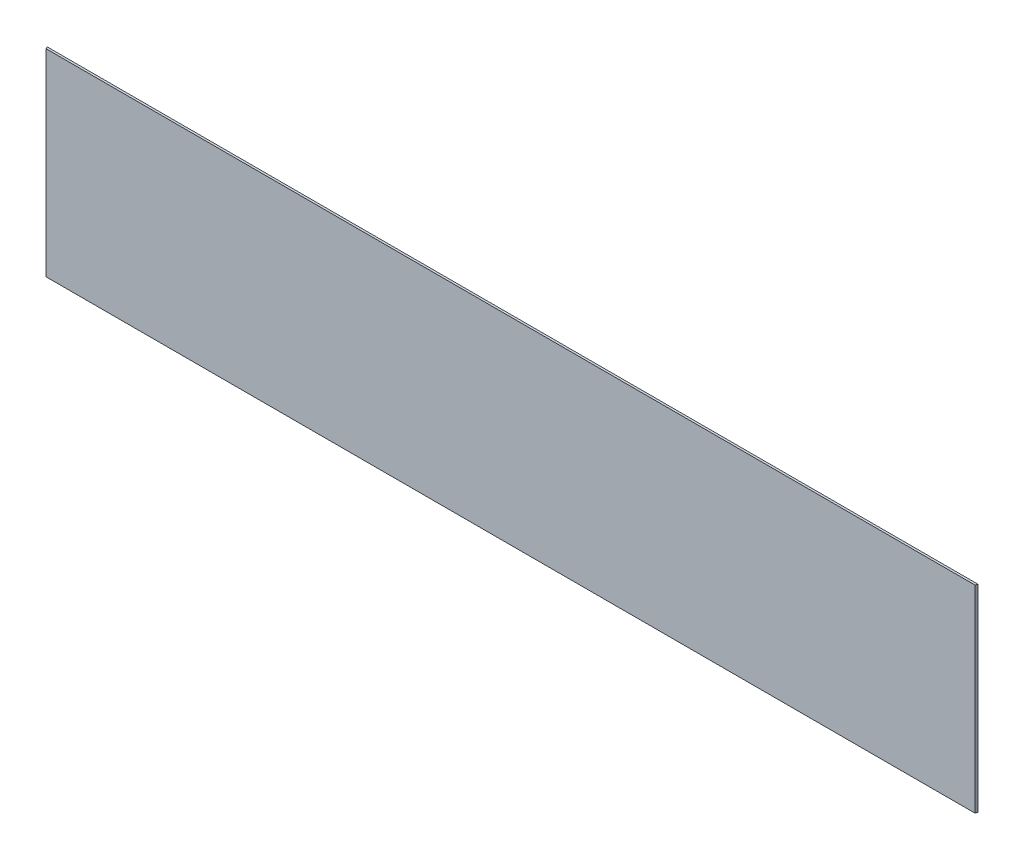
from build123d import *

# Parameters (mm, degrees)
EXTRUDE1_DEPTH = 142.875


with BuildPart() as part:
    # Sketch1 → Extrude1 (new body, symmetric)
    with BuildSketch(Plane(origin=(0, 0, 0), x_dir=(1, 0, 0), z_dir=(0, 1, 0))):
        Polygon((673.1, 1.5875), (671.784871939, -1.5875), (-671.784871939, -1.5875), (-673.1, 1.5875), align=None)
    extrude(amount=EXTRUDE1_DEPTH, both=True)


solid = part.part
